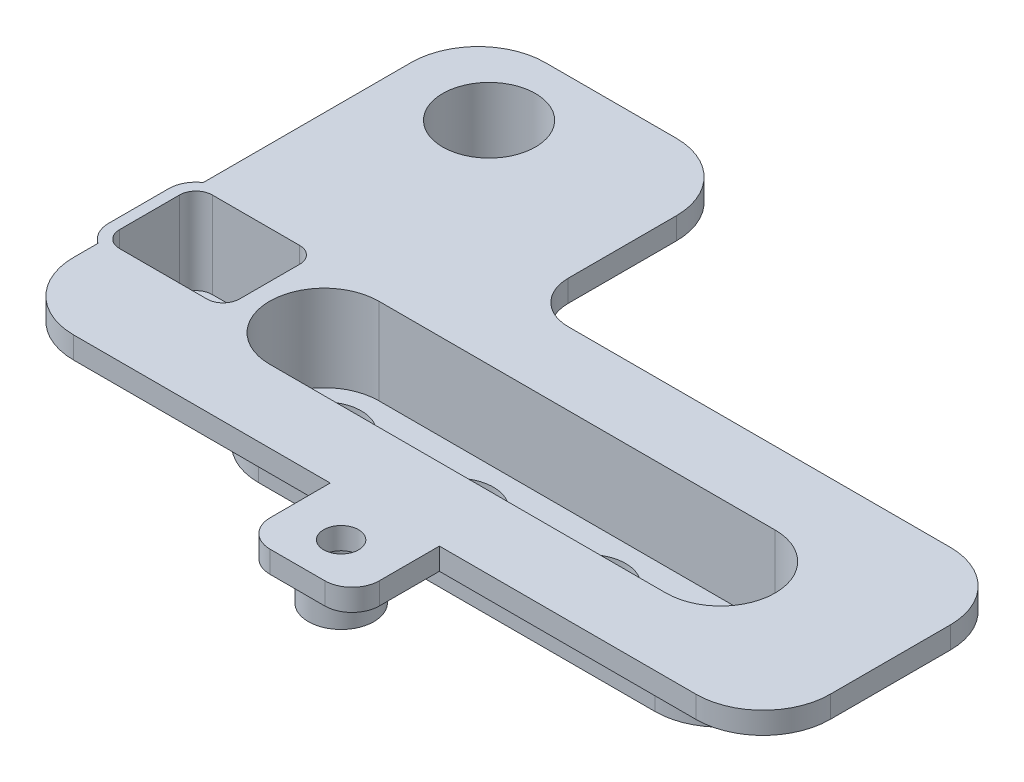
from build123d import *

# Parameters (mm, degrees)
EXTRUDE_1_DEPTH     = 2
EXTRUDE_2_DEPTH     = 8.900017028
EXTRUDE_3_DEPTH     = 8.900017028
CUT_EXTRUDE_1_DEPTH = 7.900017028
CUT_EXTRUDE_2_DEPTH = 7.900017028
SKETCH_7_R          = 4.75
EXTRUDE_4_DEPTH     = 8.9000184
SKETCH_8_R          = 4.25
CUT_EXTRUDE_3_DEPTH = 7.9000184
SKETCH_9_R          = 3.4
CUT_EXTRUDE_4_DEPTH = 50.92850157
SKETCH_10_R         = 3.55
CUT_EXTRUDE_5_DEPTH = 50.928501787
CUT_EXTRUDE_6_DEPTH = 50.92850157
EXTRUDE_5_DEPTH     = 2
SKETCH_13_R         = 3
EXTRUDE_6_DEPTH     = 3
SKETCH_14_R         = 1.6
CUT_EXTRUDE_7_DEPTH = 55.349287024
SKETCH_15_R         = 1.75
CUT_EXTRUDE_8_DEPTH = 3


with BuildPart() as part:
    # Эскиз1 → Бобышка-Вытянуть1 (new body)
    with BuildSketch(Plane(origin=(0, 0, 0), x_dir=(1, 0, 0), z_dir=(0, 1, 0))):
        with BuildLine():
            Line((35, -27.15), (-22, -27.15))
            ThreePointArc((-22, -27.15), (-26.348706704, -25.348706704), (-28.15, -21))
            Line((-28.15, -21), (-28.15, 9.9))
            ThreePointArc((-28.15, 9.9), (-26.348706704, 14.248706704), (-22, 16.05))
            Line((-22, 16.05), (-10, 16.05))
            ThreePointArc((-10, 16.05), (-5.651293296, 14.248706704), (-3.85, 9.9))
            Line((-3.85, 9.9), (-3.85, 0))
            ThreePointArc((-3.85, 0), (-2.722361108, -2.722361108), (0, -3.85))
            Line((0, -3.85), (35, -3.85))
            ThreePointArc((35, -3.85), (39.348706704, -5.651293296), (41.15, -10))
            Line((41.15, -10), (41.15, -21))
            ThreePointArc((41.15, -21), (39.348706704, -25.348706704), (35, -27.15))
        make_face()
    extrude(amount=EXTRUDE_1_DEPTH)

    # Эскиз2 → Бобышка-Вытянуть2 (add)
    with BuildSketch(Plane(origin=(0, 2, 0), x_dir=(1, 0, 0), z_dir=(0, 1, 0))):
        with BuildLine():
            Line((-10.7, -21.5), (25.6, -21.5))
            ThreePointArc((25.6, -21.5), (31.6, -15.5), (25.6, -9.5))
            Line((25.6, -9.5), (-10.7, -9.5))
            ThreePointArc((-10.7, -9.5), (-16.7, -15.5), (-10.7, -21.5))
        make_face()
    extrude(amount=-EXTRUDE_2_DEPTH)

    # Эскиз3 → Бобышка-Вытянуть3 (add)
    with BuildSketch(Plane(origin=(0, 2, 0), x_dir=(1, 0, 0), z_dir=(0, 1, 0))):
        with BuildLine():
            Line((-26.75, -19.2), (-18.75, -19.2))
            ThreePointArc((-18.75, -19.2), (-16.982233047, -18.467766953), (-16.25, -16.7))
            Line((-16.25, -16.7), (-16.25, -11.2))
            ThreePointArc((-16.25, -11.2), (-16.982233047, -9.432233047), (-18.75, -8.7))
            Line((-18.75, -8.7), (-26.75, -8.7))
            ThreePointArc((-26.75, -8.7), (-28.517766953, -9.432233047), (-29.25, -11.2))
            Line((-29.25, -11.2), (-29.25, -16.7))
            ThreePointArc((-29.25, -16.7), (-28.517766953, -18.467766953), (-26.75, -19.2))
        make_face()
    extrude(amount=-EXTRUDE_3_DEPTH)

    # Эскиз5 → Вырез-Вытянуть1 (cut)
    with BuildSketch(Plane(origin=(0, 2, 0), x_dir=(1, 0, 0), z_dir=(0, 1, 0))):
        with BuildLine():
            Line((25.6, -10.5), (-10.7, -10.5))
            ThreePointArc((-10.7, -10.5), (-15.7, -15.5), (-10.7, -20.5))
            Line((-10.7, -20.5), (25.6, -20.5))
            ThreePointArc((25.6, -20.5), (30.6, -15.5), (25.6, -10.5))
        make_face()
    extrude(amount=-CUT_EXTRUDE_1_DEPTH, mode=Mode.SUBTRACT)

    # Эскиз6 → Вырез-Вытянуть2 (cut)
    with BuildSketch(Plane(origin=(0, 2, 0), x_dir=(1, 0, 0), z_dir=(0, 1, 0))):
        with BuildLine():
            Line((-17.25, -16.7), (-17.25, -11.2))
            ThreePointArc((-17.25, -11.2), (-17.689339828, -10.139339828), (-18.75, -9.7))
            Line((-18.75, -9.7), (-26.75, -9.7))
            ThreePointArc((-26.75, -9.7), (-27.810660172, -10.139339828), (-28.25, -11.2))
            Line((-28.25, -11.2), (-28.25, -16.7))
            ThreePointArc((-28.25, -16.7), (-27.810660172, -17.760660172), (-26.75, -18.2))
            Line((-26.75, -18.2), (-18.75, -18.2))
            ThreePointArc((-18.75, -18.2), (-17.689339828, -17.760660172), (-17.25, -16.7))
        make_face()
    extrude(amount=-CUT_EXTRUDE_2_DEPTH, mode=Mode.SUBTRACT)

    # Эскиз7 → Бобышка-Вытянуть4 (add)
    with BuildSketch(Plane(origin=(0, 2, 0), x_dir=(1, 0, 0), z_dir=(0, 1, 0))):
        with Locations(Location((-20, 8.9, 0), (0, 0, 270))):
            Circle(SKETCH_7_R)
    extrude(amount=-EXTRUDE_4_DEPTH)

    # Эскиз8 → Вырез-Вытянуть3 (cut)
    with BuildSketch(Plane(origin=(0, 2, 0), x_dir=(1, 0, 0), z_dir=(0, 1, 0))):
        with Locations(Location((-20, 8.9, 0), (0, 0, 270))):
            Circle(SKETCH_8_R)
    extrude(amount=-CUT_EXTRUDE_3_DEPTH, mode=Mode.SUBTRACT)

    # Эскиз9 → Вырез-Вытянуть4 (cut, through all)
    with BuildSketch(Plane(origin=(0, -5.900017028, 0), x_dir=(1, 0, 0), z_dir=(0, 1, 0))):
        with Locations(Location((-10.7, -15.5, 0), (0, 0, 270))):
            Circle(SKETCH_9_R)
        with Locations(Location((1.4, -15.5, 0), (0, 0, 270))):
            Circle(SKETCH_9_R)
        with Locations(Location((13.5, -15.5, 0), (0, 0, 270))):
            Circle(SKETCH_9_R)
        with Locations(Location((25.6, -15.5, 0), (0, 0, 270))):
            Circle(SKETCH_9_R)
    extrude(amount=-CUT_EXTRUDE_4_DEPTH, mode=Mode.SUBTRACT)

    # Эскиз10 → Вырез-Вытянуть5 (cut, through all)
    with BuildSketch(Plane(origin=(0, -5.9000184, 0), x_dir=(1, 0, 0), z_dir=(0, 1, 0))):
        with Locations(Location((-20, 8.9, 0), (0, 0, 180))):
            Circle(SKETCH_10_R)
    extrude(amount=-CUT_EXTRUDE_5_DEPTH, mode=Mode.SUBTRACT)

    # Эскиз11 → Вырез-Вытянуть6 (cut, through all)
    with BuildSketch(Plane(origin=(0, -5.900017028, 0), x_dir=(1, 0, 0), z_dir=(0, 1, 0))):
        with BuildLine():
            Line((-27, -13.851263122), (-27, -15.6))
            ThreePointArc((-27, -15.6), (-26.794974747, -16.094974747), (-26.3, -16.3))
            Line((-26.3, -16.3), (-19.2, -16.3))
            ThreePointArc((-19.2, -16.3), (-18.705025253, -16.094974747), (-18.5, -15.6))
            Line((-18.5, -15.6), (-18.5, -13.851263122))
            ThreePointArc((-18.5, -13.851263122), (-18.543563814, -13.608175619), (-18.668832955, -13.395344741))
            Line((-18.668832955, -13.395344741), (-19.015, -12.992043329))
            Line((-19.015, -12.992043329), (-19.015, -12.3))
            ThreePointArc((-19.015, -12.3), (-19.220025253, -11.805025253), (-19.715, -11.6))
            Line((-19.715, -11.6), (-25.785, -11.6))
            ThreePointArc((-25.785, -11.6), (-26.279974747, -11.805025253), (-26.485, -12.3))
            Line((-26.485, -12.3), (-26.485, -12.992043329))
            Line((-26.485, -12.992043329), (-26.831167045, -13.395344741))
            ThreePointArc((-26.831167045, -13.395344741), (-26.956436186, -13.608175619), (-27, -13.851263122))
        make_face()
    extrude(amount=-CUT_EXTRUDE_6_DEPTH, mode=Mode.SUBTRACT)

    # Эскиз12 → Бобышка-Вытянуть5 (add)
    with BuildSketch(Plane.XZ):
        with BuildLine():
            Line((1.5, 27.15), (11.5, 27.15))
            Line((11.5, 27.15), (11.5, 32.65))
            ThreePointArc((11.5, 32.65), (10.767766953, 34.417766953), (9, 35.15))
            Line((9, 35.15), (4, 35.15))
            ThreePointArc((4, 35.15), (2.232233047, 34.417766953), (1.5, 32.65))
            Line((1.5, 32.65), (1.5, 27.15))
        make_face()
    extrude(amount=-EXTRUDE_5_DEPTH)

    # Эскиз13 → Бобышка-Вытянуть6 (add)
    with BuildSketch(Plane.XZ):
        with Locations(Location((6.5, 31.15, 0), (0, 0, 90))):
            Circle(SKETCH_13_R)
    extrude(amount=EXTRUDE_6_DEPTH)

    # Эскиз14 → Вырез-Вытянуть7 (cut, through all)
    with BuildSketch(Plane.XZ.offset(3)):
        with Locations(Location((6.5, 31.15, 0), (0, 0, 270))):
            Circle(SKETCH_14_R)
    extrude(amount=-CUT_EXTRUDE_7_DEPTH, mode=Mode.SUBTRACT)

    # Эскиз15 → Вырез-Вытянуть8 (cut)
    with BuildSketch(Plane.XZ.offset(3)):
        with Locations(Location((6.5, 31.15, 0), (0, 0, 270))):
            Circle(SKETCH_15_R)
    extrude(amount=-CUT_EXTRUDE_8_DEPTH, mode=Mode.SUBTRACT)


solid = part.part
